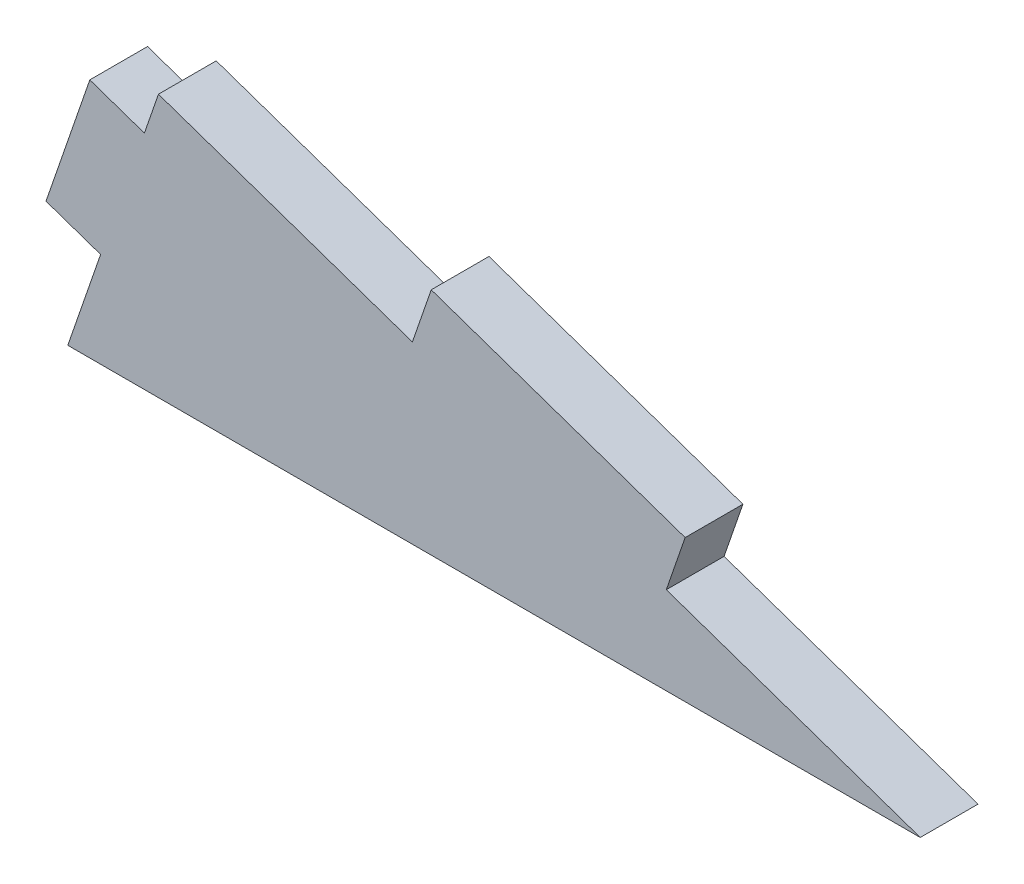
from build123d import *

# Parameters (mm, degrees)
BOSS_EXTRUDE1_DEPTH = 5.461
BOSS_EXTRUDE2_DEPTH = 5.461


with BuildPart() as part:
    # Sketch1 → Boss-Extrude1 (new body)
    with BuildSketch(Plane.XY):
        Polygon((0, 0), (80.607391231, 0), (8.573798388, 24.851589531), align=None)
    extrude(amount=BOSS_EXTRUDE1_DEPTH)

    # Sketch2 → Boss-Extrude2 (add)
    with BuildSketch(Plane.XY.offset(5.461)):
        Polygon((7.244238348, 20.997792314), (2.081830861, 22.778822897), (-2.060100727, 10.77322409), (3.10230676, 8.992193507), align=None)
        Polygon((32.584996002, 16.567726354), (56.596193616, 8.283863177), (58.377224199, 13.446270664), (34.366026585, 21.730133841), align=None)
    extrude(amount=-BOSS_EXTRUDE2_DEPTH)


solid = part.part
